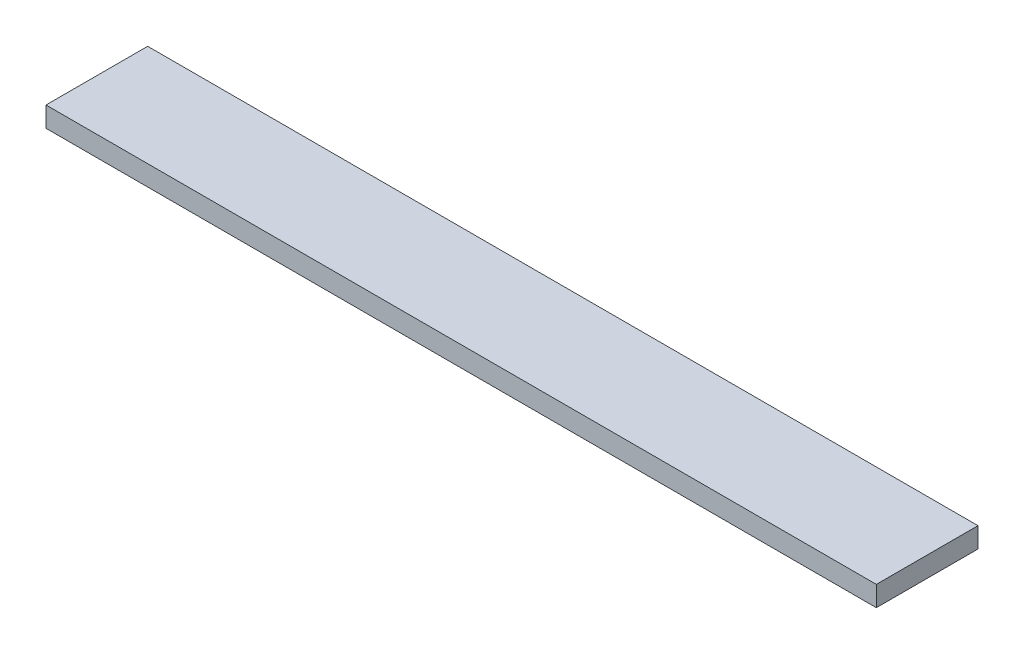
from build123d import *

# Parameters (mm, degrees)
SKETCH1_W           = 781.84375
SKETCH1_H           = 95.73895
BOSS_EXTRUDE1_DEPTH = 19.05


with BuildPart() as part:
    # Sketch1 → Boss-Extrude1 (new body)
    with BuildSketch(Plane(origin=(0, 0, 0), x_dir=(1, 0, 0), z_dir=(0, 1, 0))):
        with Locations((390.921875, 47.869475)):
            Rectangle(SKETCH1_W, SKETCH1_H)
    extrude(amount=BOSS_EXTRUDE1_DEPTH)


solid = part.part
